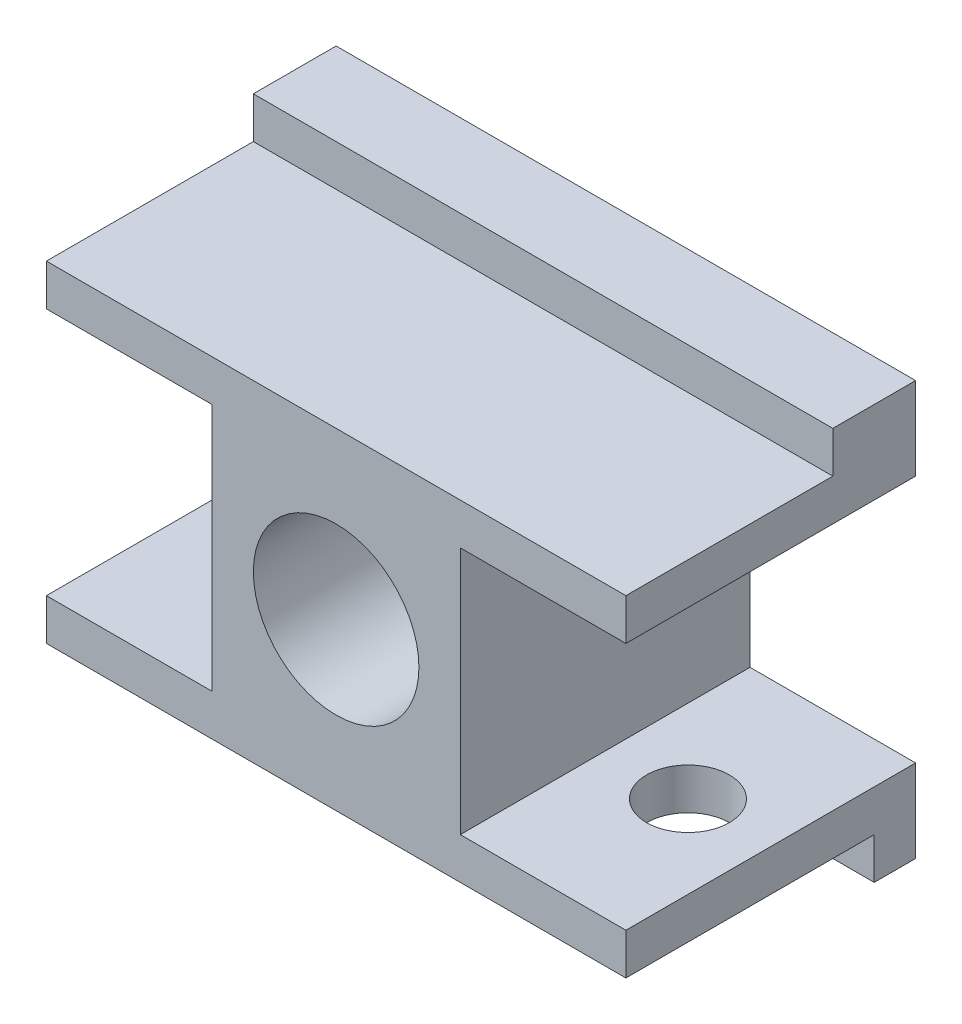
from build123d import *

# Parameters (mm, degrees)
SKETCH1_W           = 70
SKETCH1_H           = 5
BOSS_EXTRUDE1_DEPTH = 10
SKETCH2_W           = 70
SKETCH2_H           = 5
BOSS_EXTRUDE2_DEPTH = 30
SKETCH3_R           = 5
CUT_EXTRUDE2_DEPTH  = 10
SKETCH4_R           = 5
CUT_EXTRUDE3_DEPTH  = 10
SKETCH6_W           = 30
SKETCH6_H           = 35
BOSS_EXTRUDE4_DEPTH = 30
BOSS_EXTRUDE5_DEPTH = 5
SKETCH8_W           = 70
SKETCH8_H           = 10
BOSS_EXTRUDE6_DEPTH = 5
SKETCH9_R           = 10
CUT_EXTRUDE4_DEPTH  = 30


with BuildPart() as part:
    # Sketch1 → Boss-Extrude1 (new body)
    with BuildSketch(Plane(origin=(0, 0, 0), x_dir=(1, 0, 0), z_dir=(0, 1, 0))):
        with Locations((35, 2.5)):
            Rectangle(SKETCH1_W, SKETCH1_H)
    extrude(amount=BOSS_EXTRUDE1_DEPTH)

    # Sketch2 → Boss-Extrude2 (add)
    with BuildSketch(Plane.XY):
        with Locations((35, 7.5)):
            Rectangle(SKETCH2_W, SKETCH2_H)
    extrude(amount=BOSS_EXTRUDE2_DEPTH)

    # Sketch3 → Cut-Extrude2 (cut)
    with BuildSketch(Plane(origin=(0, 0, 0), x_dir=(1, 0, 0), z_dir=(0, 1, 0))):
        with Locations((60, -12.5)):
            Circle(SKETCH3_R)
    extrude(amount=CUT_EXTRUDE2_DEPTH, mode=Mode.SUBTRACT)

    # Sketch4 → Cut-Extrude3 (cut)
    with BuildSketch(Plane(origin=(0, 0, 0), x_dir=(1, 0, 0), z_dir=(0, 1, 0))):
        with Locations((10, -12.5)):
            Circle(SKETCH4_R)
    extrude(amount=CUT_EXTRUDE3_DEPTH, mode=Mode.SUBTRACT)

    # Sketch6 → Boss-Extrude4 (add)
    with BuildSketch(Plane(origin=(0, 10, 0), x_dir=(1, 0, 0), z_dir=(0, 1, 0))):
        with Locations((35, -12.5)):
            Rectangle(SKETCH6_W, SKETCH6_H)
    extrude(amount=BOSS_EXTRUDE4_DEPTH)

    # Sketch7 → Boss-Extrude5 (add)
    with BuildSketch(Plane(origin=(0, 40, 0), x_dir=(1, 0, 0), z_dir=(0, 1, 0))):
        Polygon((20, 5), (0, 5), (0, -30), (70, -30), (70, 5), align=None)
    extrude(amount=BOSS_EXTRUDE5_DEPTH)

    # Sketch8 → Boss-Extrude6 (add)
    with BuildSketch(Plane(origin=(0, 45, 0), x_dir=(1, 0, 0), z_dir=(0, 1, 0))):
        with Locations((35, 0)):
            Rectangle(SKETCH8_W, SKETCH8_H)
    extrude(amount=BOSS_EXTRUDE6_DEPTH)

    # Sketch9 → Cut-Extrude4 (cut)
    with BuildSketch(Plane.XY.offset(30)):
        with Locations((35, 25)):
            Circle(SKETCH9_R)
    extrude(amount=-CUT_EXTRUDE4_DEPTH, mode=Mode.SUBTRACT)


solid = part.part
